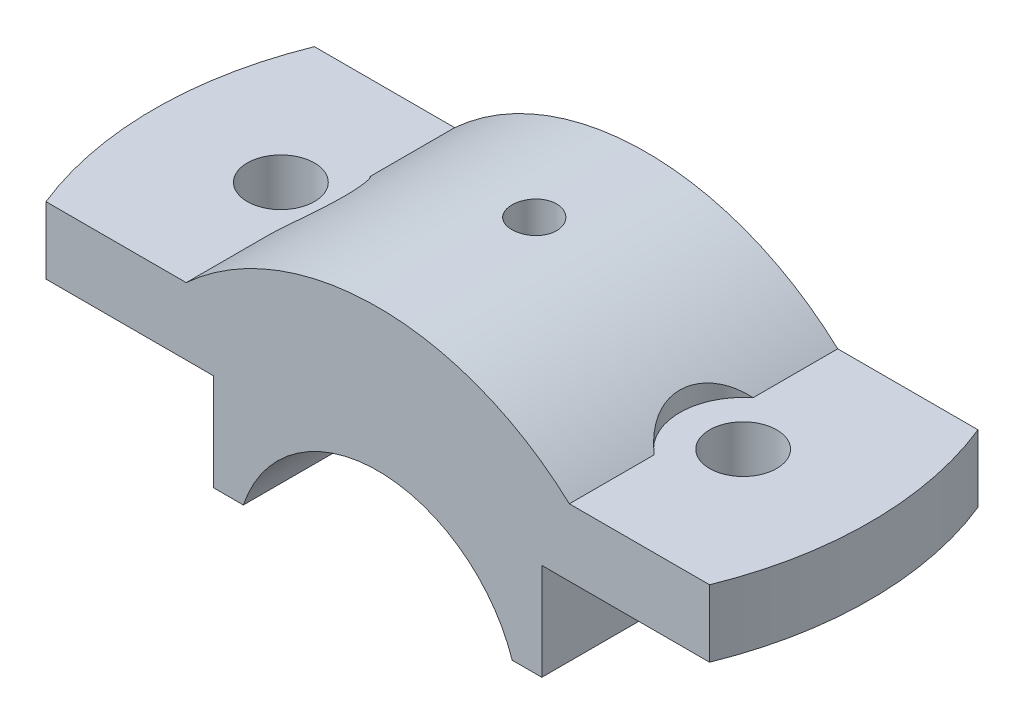
from build123d import *

# Parameters (mm, degrees)
BOSS_EXTRUDE1_DEPTH    = 18
CUT_EXTRUDE1_DEPTH     = 23
F_12_0MM_DOWEL_HOLE3_D = 9
CUT_EXTRUDE5_DEPTH     = 36


with BuildPart() as part:
    # Sketch1 → Boss-Extrude1 (new body, symmetric)
    with BuildSketch(Plane.XY):
        with BuildLine():
            Line((18.027756377, 6), (22, 6))
            Line((22, 6), (22, 19))
            Line((22, 19), (50, 19))
            Line((50, 19), (50, 28))
            Line((50, 28), (25.690465157, 28))
            ThreePointArc((25.690465157, 28), (0, 38), (-25.690465157, 28))
            Line((-25.690465157, 28), (-50, 28))
            Line((-50, 28), (-50, 19))
            Line((-50, 19), (-22, 19))
            Line((-22, 19), (-22, 6))
            Line((-22, 6), (-18.027756377, 6))
            ThreePointArc((-18.027756377, 6), (0, 19), (18.027756377, 6))
        make_face()
    extrude(amount=BOSS_EXTRUDE1_DEPTH, both=True)

    # Sketch3 → Cut-Extrude1 (cut, through all)
    with BuildSketch(Plane(origin=(0, 28, 0), x_dir=(1, 0, 0), z_dir=(0, 1, 0))):
        with BuildLine():
            Line((-44.497190923, 18), (-50, 18))
            Line((-50, 18), (-50, -18))
            Line((-50, -18), (-44.497190923, -18))
            ThreePointArc((-44.497190923, -18), (-48, 0), (-44.497190923, 18))
        make_face()
    cut_extrude1 = extrude(amount=-CUT_EXTRUDE1_DEPTH, mode=Mode.SUBTRACT)

    # Ø12.0mm Dowel Hole3 (through all)
    with Locations(Plane(origin=(0, 28, 0), x_dir=(1, 0, 0), z_dir=(0, 1, 0))):
        with Locations((-31, 0)):
            f_12_0mm_dowel_hole3 = Hole(F_12_0MM_DOWEL_HOLE3_D / 2)

    # Sketch17 → Cut-Extrude5 (cut)
    with BuildSketch(Plane(origin=(0, 28, 0), x_dir=(1, 0, 0), z_dir=(0, 1, 0))):
        with BuildLine():
            Line((-25.690465157, -6.637683312), (-25.690465157, 6.637683312))
            ThreePointArc((-25.690465157, 6.637683312), (-22.5, 0), (-25.690465157, -6.637683312))
        make_face()
    cut_extrude5 = extrude(amount=CUT_EXTRUDE5_DEPTH, mode=Mode.SUBTRACT)

    # Sketch20 → CBORE for M6 Hex Head Bolt1 (revolve, cut)
    with BuildSketch(Plane(origin=(0, 38, -2.983943356), x_dir=(0, 0, 1), z_dir=(1, 0, 0))):
        Polygon((0, 0), (0, 32), (2.5, 32), (2.5, 13.495), (2.995, 13), (3, 13), (3, 0), align=None)
    revolve(axis=Axis((0, 44.35, -2.983943356), (0, -1, 0)), mode=Mode.SUBTRACT)

    # Mirror1: Cut-Extrude1, Ø12.0mm Dowel Hole3, Cut-Extrude5 across plane
    add(cut_extrude1.mirror(Plane(origin=(0, 0, 0), x_dir=(0, 0, 1), z_dir=(1, 0, 0))), mode=Mode.SUBTRACT)
    add(f_12_0mm_dowel_hole3.mirror(Plane(origin=(0, 0, 0), x_dir=(0, 0, 1), z_dir=(1, 0, 0))), mode=Mode.SUBTRACT)
    add(cut_extrude5.mirror(Plane(origin=(0, 0, 0), x_dir=(0, 0, 1), z_dir=(1, 0, 0))), mode=Mode.SUBTRACT)


solid = part.part
